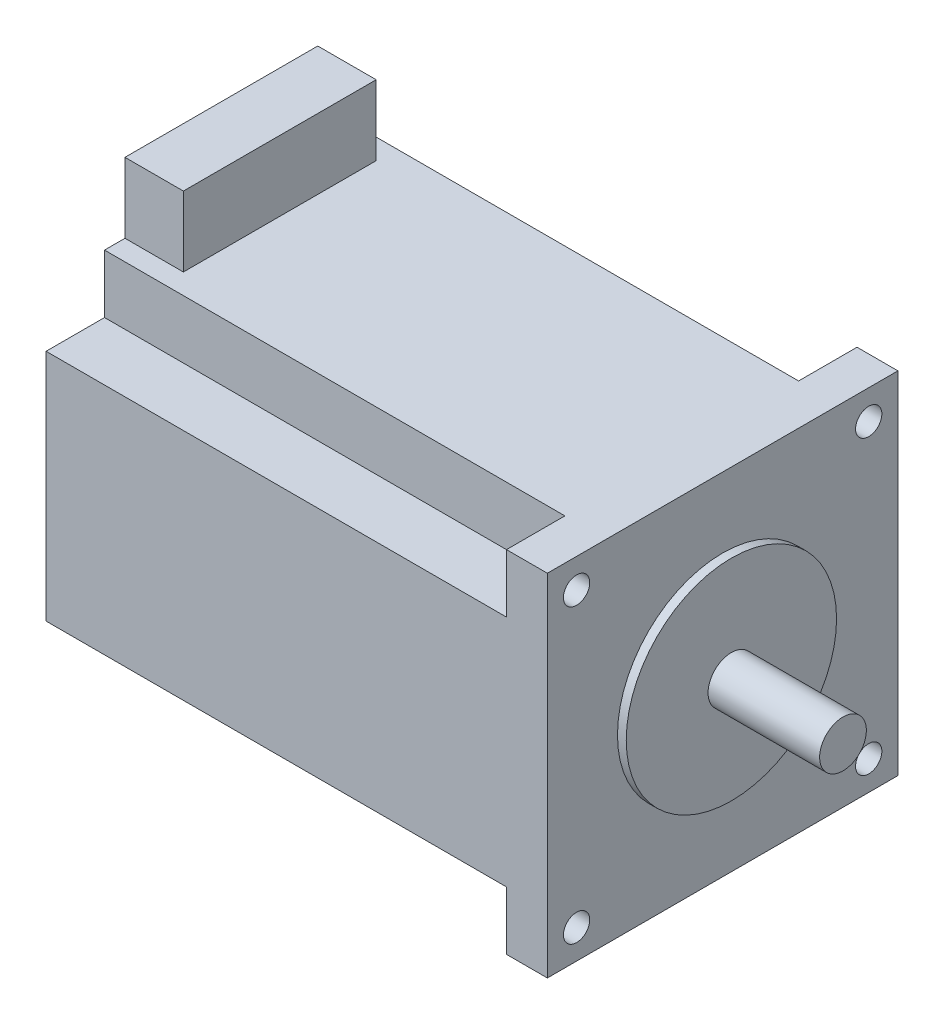
from build123d import *

# Parameters (mm, degrees)
SKETCH1_W          = 85.8
SKETCH1_H          = 60
EXTRUDE1_DEPTH     = 30
SKETCH1_5_W        = 10
SKETCH1_5_H        = 12
EXTRUDE2_DEPTH     = 16.5
SKETCH2_R          = 18
SKETCH2_R_2        = 4
EXTRUDE3_DEPTH     = 1.5
SKETCH2_2_R        = 18
SKETCH2_2_R_2      = 4
EXTRUDE4_DEPTH     = 1.5
SKETCH4_R          = 4
EXTRUDE5_DEPTH     = 20.6
SKETCH5_R          = 2.25
CUT_EXTRUDE1_DEPTH = 86
SKETCH6_W          = 10
SKETCH6_H          = 10
CUT_EXTRUDE2_DEPTH = 78.8


with BuildPart() as part:
    # Sketch1 → Extrude1 (new body, symmetric)
    with BuildSketch(Plane.XY):
        with Locations((42.9, 30)):
            Rectangle(SKETCH1_W, SKETCH1_H)
    extrude(amount=EXTRUDE1_DEPTH, both=True)

    # Sketch1_5 → Extrude2 (add, symmetric)
    with BuildSketch(Plane.XY):
        with Locations((5, 66)):
            Rectangle(SKETCH1_5_W, SKETCH1_5_H)
    extrude(amount=EXTRUDE2_DEPTH, both=True)

    # Sketch2 → Extrude3 (add)
    with BuildSketch(Plane(origin=(85.8, 0, 0), x_dir=(0, 0, -1), z_dir=(1, 0, 0))):
        with Locations((0, 30)):
            Circle(SKETCH2_R)
        with Locations((0, 30)):
            Circle(SKETCH2_R_2, mode=Mode.SUBTRACT)
    extrude(amount=EXTRUDE3_DEPTH)

    # Sketch2_2 → Extrude4 (add)
    with BuildSketch(Plane(origin=(85.8, 0, 0), x_dir=(0, 0, -1), z_dir=(1, 0, 0))):
        with Locations((0, 30)):
            Circle(SKETCH2_2_R)
        with Locations((0, 30)):
            Circle(SKETCH2_2_R_2, mode=Mode.SUBTRACT)
    extrude(amount=EXTRUDE4_DEPTH)

    # Sketch4 → Extrude5 (add)
    with BuildSketch(Plane(origin=(85.8, 0, 0), x_dir=(0, 0, -1), z_dir=(1, 0, 0))):
        with Locations((0, 30)):
            Circle(SKETCH4_R)
    extrude(amount=EXTRUDE5_DEPTH)

    # Sketch5 → Cut-Extrude1 (cut)
    with BuildSketch(Plane(origin=(85.8, 0, 0), x_dir=(0, 0, -1), z_dir=(1, 0, 0))):
        with Locations((-25, 55)):
            Circle(SKETCH5_R)
        with Locations((25, 55)):
            Circle(SKETCH5_R)
        with Locations((25, 5)):
            Circle(SKETCH5_R)
        with Locations((-25, 5)):
            Circle(SKETCH5_R)
    extrude(amount=-CUT_EXTRUDE1_DEPTH, mode=Mode.SUBTRACT)

    # Sketch6 → Cut-Extrude2 (cut)
    with BuildSketch(Plane.ZY):
        with Locations((-25, 55)):
            Rectangle(SKETCH6_W, SKETCH6_H)
        with Locations((25, 55)):
            Rectangle(SKETCH6_W, SKETCH6_H)
        with Locations((-25, 5)):
            Rectangle(SKETCH6_W, SKETCH6_H)
        with Locations((25, 5)):
            Rectangle(SKETCH6_W, SKETCH6_H)
    extrude(amount=-CUT_EXTRUDE2_DEPTH, mode=Mode.SUBTRACT)


solid = part.part
